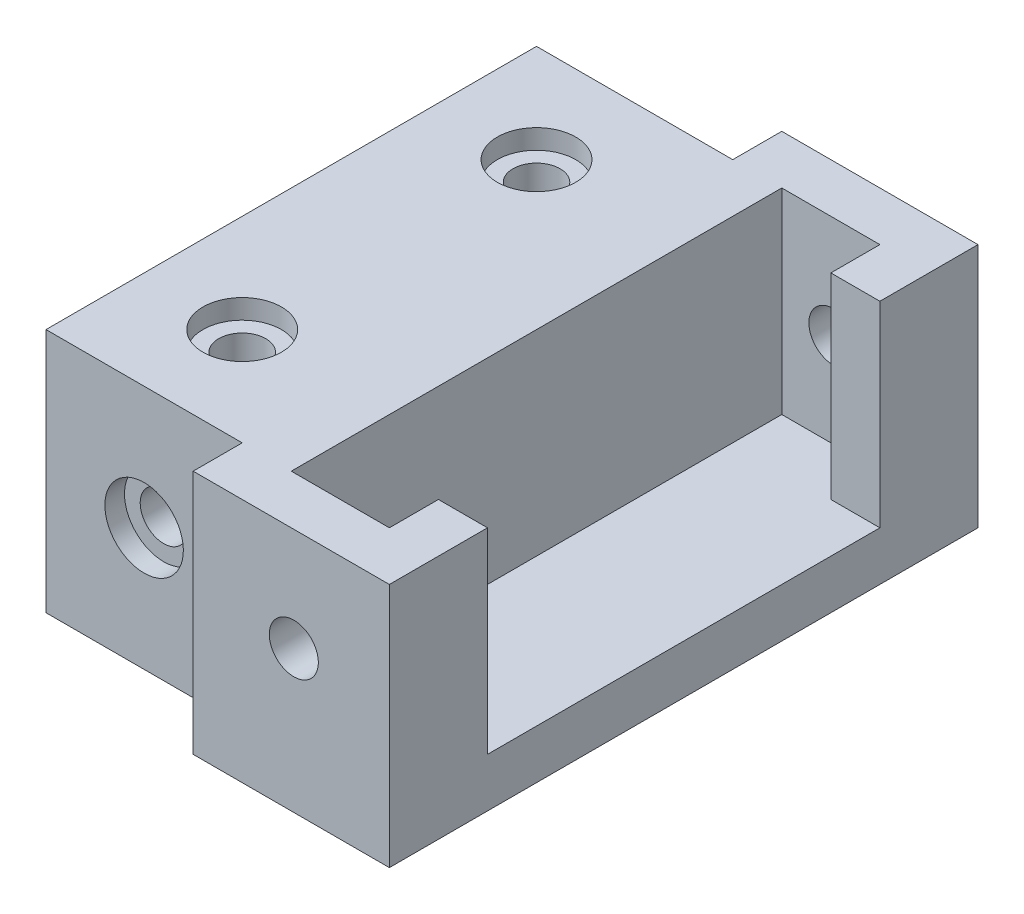
from build123d import *

# Parameters (mm, degrees)
BOSS_EXTRU_1_DEPTH                                = 20
ESQUISSE1_3_W                                     = 20
ESQUISSE1_3_H                                     = 60
BOSS_EXTRU_2_DEPTH                                = 5
BOSS_EXTRU_3_DEPTH                                = 20
ENL_V_MAT_EXTRU_2_DEPTH                           = 40
ENL_V_MAT_EXTRU_2_DEPTH_BACK                      = 67.332495807
ESQUISSE4_R                                       = 2.5
CHAMBRAGE_POUR_VIS_SIX_PANS_CREUX_M41_D           = 4.8
CHAMBRAGE_POUR_VIS_SIX_PANS_CREUX_M41_CBORE_D     = 8
CHAMBRAGE_POUR_VIS_SIX_PANS_CREUX_M41_CBORE_DEPTH = 2
CHAMBRAGE_POUR_VIS_SIX_PANS_CREUX_2_D             = 4.8
CHAMBRAGE_POUR_VIS_SIX_PANS_CREUX_2_CBORE_D       = 8
CHAMBRAGE_POUR_VIS_SIX_PANS_CREUX_2_CBORE_DEPTH   = 2
CHAMBRAGE_POUR_VIS_SIX_PANS_CREUX_3_D             = 4.8
CHAMBRAGE_POUR_VIS_SIX_PANS_CREUX_3_CBORE_D       = 8
CHAMBRAGE_POUR_VIS_SIX_PANS_CREUX_3_CBORE_DEPTH   = 2


with BuildPart() as part:
    # Esquisse1 → Boss.-Extru.1 (new body)
    with BuildSketch(Plane(origin=(0, 0, 0), x_dir=(1, 0, 0), z_dir=(0, 1, 0))):
        Polygon((15, 5), (5, 5), (5, 55), (15, 55), (15, 50), (20, 50), (20, 60), (0, 60), (0, 0), (20, 0), (20, 10), (15, 10), align=None)
    extrude(amount=BOSS_EXTRU_1_DEPTH)

    # Esquisse1_3 → Boss.-Extru.2 (add)
    with BuildSketch(Plane(origin=(0, 0, 0), x_dir=(1, 0, 0), z_dir=(0, 1, 0))):
        with Locations((10, 30)):
            Rectangle(ESQUISSE1_3_W, ESQUISSE1_3_H)
    extrude(amount=-BOSS_EXTRU_2_DEPTH)

    # Esquisse3 → Boss.-Extru.3 (add)
    with BuildSketch(Plane.ZY):
        Polygon((-55, 20), (-55, -5), (-50, -5), (-50, 15), (-10, 15), (-10, -5), (-5, -5), (-5, 20), align=None)
    extrude(amount=BOSS_EXTRU_3_DEPTH)

    # Esquisse4 → Enlèv. mat.-Extru.2 (cut, two sides: drawn at the far end of the back side and taken through both)
    with BuildSketch(Plane.XY.offset(-ENL_V_MAT_EXTRU_2_DEPTH_BACK)):
        with Locations((10.259432597, 9.481134806)):
            Circle(ESQUISSE4_R)
    extrude(amount=ENL_V_MAT_EXTRU_2_DEPTH + ENL_V_MAT_EXTRU_2_DEPTH_BACK, mode=Mode.SUBTRACT)

    # Chambrage pour vis à six pans creux M41 (through all)
    with Locations(Plane(origin=(-10, 7.5, -5), x_dir=(0, 1, 0), z_dir=(0, 0, 1))):
        with Locations((0, 0)):
            CounterBoreHole(CHAMBRAGE_POUR_VIS_SIX_PANS_CREUX_M41_D / 2, CHAMBRAGE_POUR_VIS_SIX_PANS_CREUX_M41_CBORE_D / 2, CHAMBRAGE_POUR_VIS_SIX_PANS_CREUX_M41_CBORE_DEPTH)

    # Chambrage pour vis _ six pans creux  2 (through all)
    with Locations(Plane(origin=(-10, 20, -45), x_dir=(0, 0, 1), z_dir=(0, 1, 0))):
        with Locations((0, 0), (30, 0)):
            CounterBoreHole(CHAMBRAGE_POUR_VIS_SIX_PANS_CREUX_2_D / 2, CHAMBRAGE_POUR_VIS_SIX_PANS_CREUX_2_CBORE_D / 2, CHAMBRAGE_POUR_VIS_SIX_PANS_CREUX_2_CBORE_DEPTH)

    # Chambrage pour vis _ six pans creux  3 (through all)
    with Locations(Plane(origin=(-10, 7.5, -55), x_dir=(-1, 0, 0), z_dir=(0, 0, -1))):
        with Locations((0, 0)):
            CounterBoreHole(CHAMBRAGE_POUR_VIS_SIX_PANS_CREUX_3_D / 2, CHAMBRAGE_POUR_VIS_SIX_PANS_CREUX_3_CBORE_D / 2, CHAMBRAGE_POUR_VIS_SIX_PANS_CREUX_3_CBORE_DEPTH)


solid = part.part
